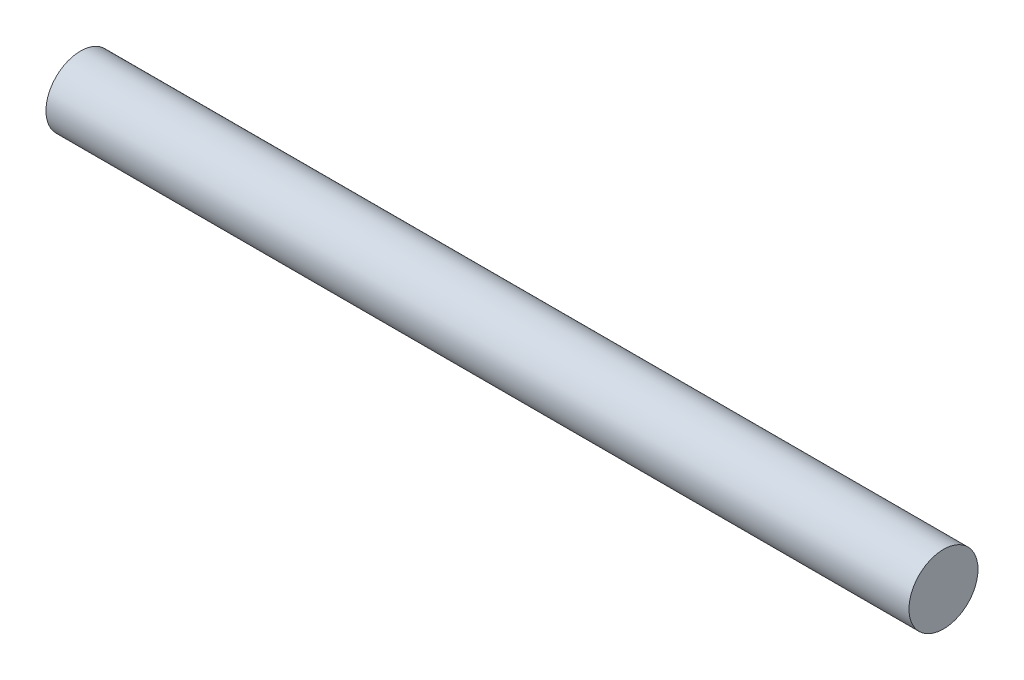
from build123d import *

# Parameters (mm, degrees)
SKETCH1_R           = 0.8
BOSS_EXTRUDE1_DEPTH = 20


with BuildPart() as part:
    # Sketch1 → Boss-Extrude1 (new body)
    with BuildSketch(Plane(origin=(0, 0, 0), x_dir=(0, 0, -1), z_dir=(1, 0, 0))):
        with Locations((-4.936604701, 1.178890675)):
            Circle(SKETCH1_R)
    extrude(amount=BOSS_EXTRUDE1_DEPTH)


solid = part.part
